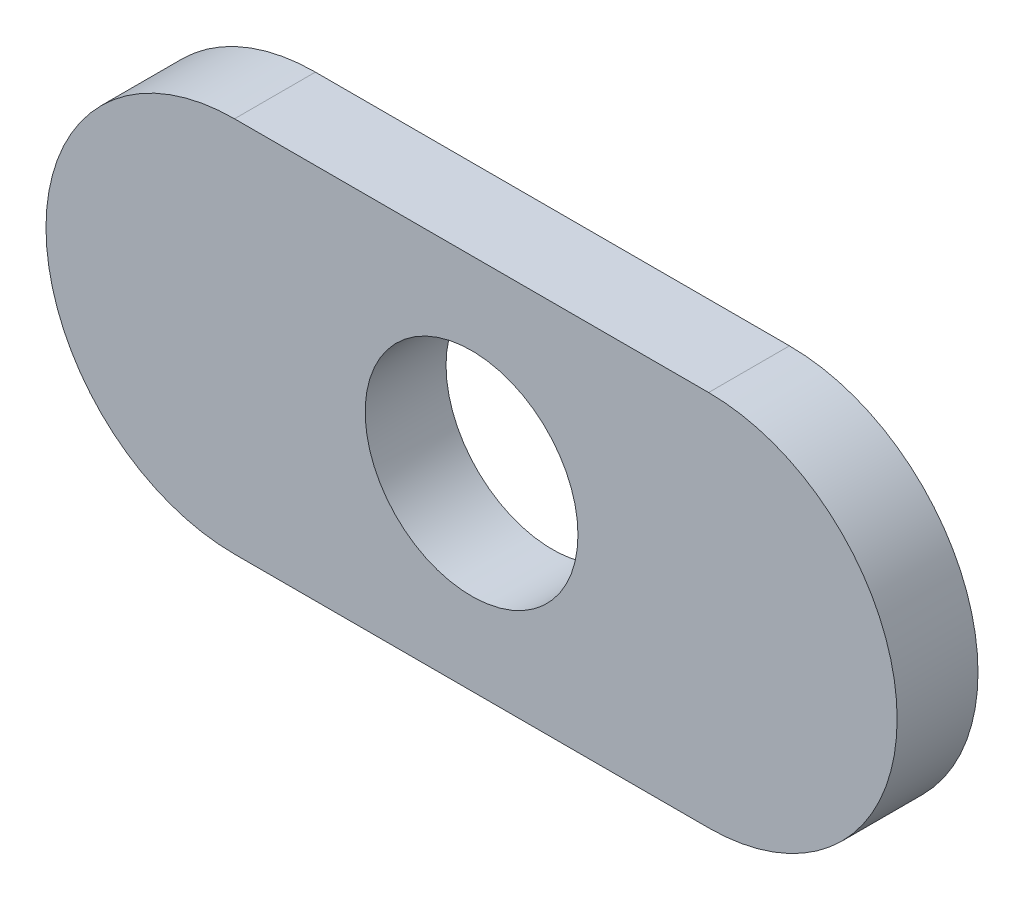
from build123d import *

# Parameters (mm, degrees)
EXTRUDE1_DEPTH     = 2.413
CUT_EXTRUDE1_REACH = 4.413
SKETCH4_R          = 3.175


with BuildPart() as part:
    # Sketch1 → Extrude1 (new body)
    with BuildSketch(Plane.XY):
        with BuildLine():
            Line((111.27866266, 131.559165896), (125.42646266, 131.559165896))
            ThreePointArc((125.42646266, 131.559165896), (131.05256266, 125.933065896), (125.42646266, 120.306965896))
            Line((125.42646266, 120.306965896), (111.27866266, 120.306965896))
            ThreePointArc((111.27866266, 120.306965896), (105.65256266, 125.933065896), (111.27866266, 131.559165896))
        make_face()
    extrude(amount=EXTRUDE1_DEPTH)

    # Sketch4 → Cut-Extrude1 (cut, up to next)
    with BuildSketch(Plane.XY.offset(2.413), mode=Mode.PRIVATE) as cut_extrude1_sk1:
        with Locations((118.35256266, 125.933065896)):
            Circle(SKETCH4_R)
    cut_extrude1_tool1 = extrude(cut_extrude1_sk1.sketch, amount=-CUT_EXTRUDE1_REACH, mode=Mode.PRIVATE) & part.part
    add(cut_extrude1_tool1.solids().sort_by_distance((118.352563, 125.933066, 2.413))[0], mode=Mode.SUBTRACT)


solid = part.part
